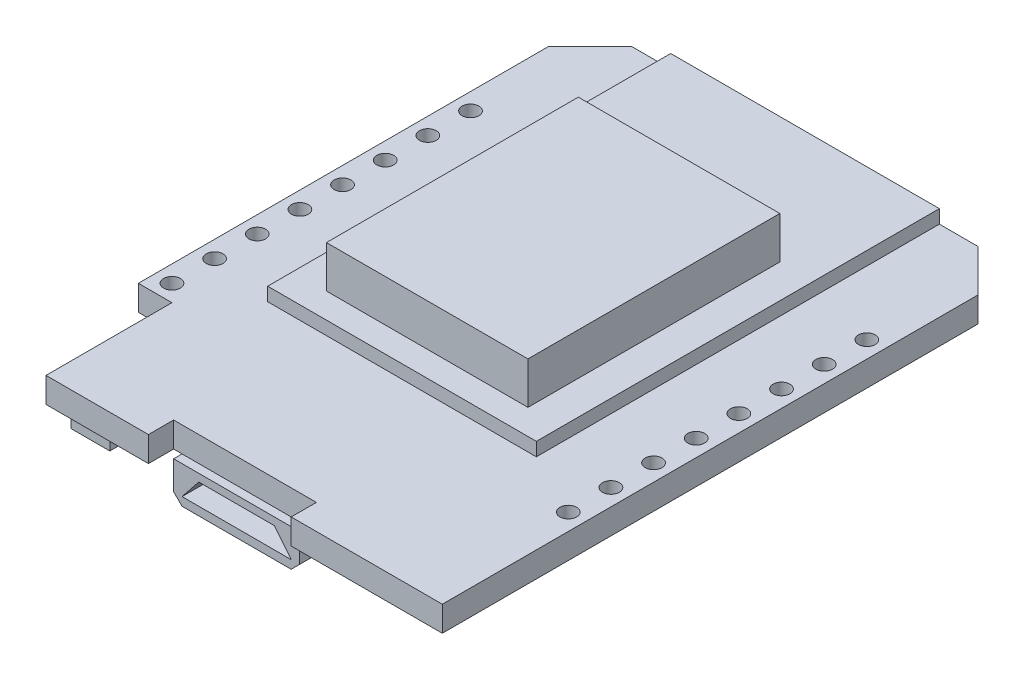
from build123d import *

# Parameters (mm, degrees)
SKETCH1_R               = 0.5
PCB_DEPTH               = 1.5
SKETCH2_W               = 16
SKETCH2_H               = 24
ESP8266_PCB_DEPTH       = 0.8
SKETCH3_W               = 12
SKETCH3_H               = 15
ESP8266_RF_SHIELD_DEPTH = 2.5
SKETCH5_W               = 7.5
SKETCH5_H               = 5.6
BOSS_EXTRUDE4_DEPTH     = 2.2
CHAMFER1_SIZE           = 0.5
CUT_EXTRUDE1_DEPTH      = 4
SKETCH5_4_W             = 2.3
SKETCH5_4_H             = 4.5
BUTTON_BODY_DEPTH       = 2
SKETCH11_W              = 2
SKETCH11_H              = 0.89493309
BUTTON_ACTUATOR_DEPTH   = 1
SKETCH5_5_W             = 1.5
SKETCH5_5_H             = 1
COMPONENTS1_DEPTH       = 1
SKETCH5_5_W_2           = 10.115707705
SKETCH5_5_H_2           = 4.574950916
COMPONENTS1_2_DEPTH     = 1
COMPONENTS1_3_DEPTH     = 1
COMPONENTS1_4_DEPTH     = 1
SKETCH5_5_W_3           = 1
SKETCH5_5_H_3           = 1.5
COMPONENTS1_5_DEPTH     = 1
SKETCH5_6_W             = 1.5
SKETCH5_6_H             = 1
COMPONENTS_2_DEPTH      = 0.5
COMPONENTS_2_2_DEPTH    = 0.5
COMPONENTS_2_3_DEPTH    = 0.5
COMPONENTS_2_4_DEPTH    = 0.5
COMPONENTS_2_5_DEPTH    = 0.5
COMPONENTS_2_6_DEPTH    = 0.5
COMPONENTS_2_7_DEPTH    = 0.5
COMPONENTS_2_8_DEPTH    = 0.5
COMPONENTS_2_9_DEPTH    = 0.5
SKETCH5_6_W_2           = 1
SKETCH5_6_H_2           = 2.730487257
COMPONENTS_2_10_DEPTH   = 0.5
COMPONENTS_2_11_DEPTH   = 0.5
SKETCH5_6_H_3           = 1.5
COMPONENTS_2_12_DEPTH   = 0.5
COMPONENTS_2_13_DEPTH   = 0.5
COMPONENTS_2_14_DEPTH   = 0.5
COMPONENTS_2_15_DEPTH   = 0.5
COMPONENTS_2_16_DEPTH   = 0.5
COMPONENTS_2_17_DEPTH   = 0.5
COMPONENTS_2_18_DEPTH   = 0.5
COMPONENTS_2_19_DEPTH   = 0.5
COMPONENTS_2_20_DEPTH   = 0.5
COMPONENTS_2_21_DEPTH   = 0.5


with BuildPart() as part:
    # Sketch1 → PCB (new body)
    with BuildSketch(Plane(origin=(0, 0, 0), x_dir=(1, 0, 0), z_dir=(0, 1, 0))):
        Polygon((0, 0), (0, 31.9), (-2.5, 34.4), (-23.1, 34.4), (-25.6, 31.9), (-25.6, 7.5), (-23.6, 7.5), (-23.6, 0), (-17.5, 0), (-17.5, 1.5), (-9, 1.5), (-9, 0), align=None)
        with Locations((-24.6, 8.5)):
            Circle(SKETCH1_R, mode=Mode.SUBTRACT)
        with Locations((-1, 8.5)):
            Circle(SKETCH1_R, mode=Mode.SUBTRACT)
        with Locations((-24.6, 11.04)):
            Circle(SKETCH1_R, mode=Mode.SUBTRACT)
        with Locations((-1, 11.04)):
            Circle(SKETCH1_R, mode=Mode.SUBTRACT)
        with Locations((-24.6, 13.58)):
            Circle(SKETCH1_R, mode=Mode.SUBTRACT)
        with Locations((-1, 13.58)):
            Circle(SKETCH1_R, mode=Mode.SUBTRACT)
        with Locations((-24.6, 16.12)):
            Circle(SKETCH1_R, mode=Mode.SUBTRACT)
        with Locations((-1, 16.12)):
            Circle(SKETCH1_R, mode=Mode.SUBTRACT)
        with Locations((-24.6, 18.66)):
            Circle(SKETCH1_R, mode=Mode.SUBTRACT)
        with Locations((-1, 18.66)):
            Circle(SKETCH1_R, mode=Mode.SUBTRACT)
        with Locations((-24.6, 21.2)):
            Circle(SKETCH1_R, mode=Mode.SUBTRACT)
        with Locations((-1, 21.2)):
            Circle(SKETCH1_R, mode=Mode.SUBTRACT)
        with Locations((-24.6, 23.74)):
            Circle(SKETCH1_R, mode=Mode.SUBTRACT)
        with Locations((-1, 23.74)):
            Circle(SKETCH1_R, mode=Mode.SUBTRACT)
        with Locations((-24.6, 26.28)):
            Circle(SKETCH1_R, mode=Mode.SUBTRACT)
        with Locations((-1, 26.28)):
            Circle(SKETCH1_R, mode=Mode.SUBTRACT)
    extrude(amount=PCB_DEPTH)


with BuildPart() as body_2:
    # Sketch2 → ESP8266 PCB (new body)
    with BuildSketch(Plane(origin=(0, 1.5, 0), x_dir=(1, 0, 0), z_dir=(0, 1, 0))):
        with Locations((-12.8, 22.4)):
            Rectangle(SKETCH2_W, SKETCH2_H)
    extrude(amount=ESP8266_PCB_DEPTH)


with BuildPart() as body_3:
    # Sketch3 → ESP8266 Rf Shield (new body)
    with BuildSketch(Plane(origin=(0, 2.3, 0), x_dir=(1, 0, 0), z_dir=(0, 1, 0))):
        with Locations((-12.8, 19.4)):
            Rectangle(SKETCH3_W, SKETCH3_H)
    extrude(amount=ESP8266_RF_SHIELD_DEPTH)


with BuildPart() as body_4:
    # Sketch5 → Boss-Extrude4 (new body)
    with BuildSketch(Plane.XZ):
        with Locations((-13.25, -3.8)):
            Rectangle(SKETCH5_W, SKETCH5_H)
    extrude(amount=BOSS_EXTRUDE4_DEPTH)

    # Chamfer1
    chamfer1_edges = [body_4.edges().sort_by_distance(p)[0] for p in [
        (-17, -2.2, -3.8),
        (-9.5, -2.2, -3.8),
    ]]
    chamfer(chamfer1_edges, length=CHAMFER1_SIZE)

    # Sketch12 → Cut-Extrude1 (cut)
    with BuildSketch(Plane.XY.offset(-1)):
        Polygon((-15.5, -0.45), (-11, -0.45), (-10, -1.7), (-16.5, -1.7), align=None)
    extrude(amount=-CUT_EXTRUDE1_DEPTH, mode=Mode.SUBTRACT)


with BuildPart() as body_5:
    # Sketch5_4 → Button Body (new body)
    with BuildSketch(Plane.XZ):
        with Locations((-22.45, -3.75)):
            Rectangle(SKETCH5_4_W, SKETCH5_4_H)
    extrude(amount=BUTTON_BODY_DEPTH)


with BuildPart() as body_6:
    # Sketch11 → Button Actuator (new body)
    with BuildSketch(Plane.ZY.offset(23.6)):
        with Locations((-3.75, -1)):
            Rectangle(SKETCH11_W, SKETCH11_H)
    extrude(amount=BUTTON_ACTUATOR_DEPTH)


with BuildPart() as body_7:
    # Sketch5_5 → Components1 (new body)
    with BuildSketch(Plane.XZ):
        with Locations((-3.164431534, -3.205591578)):
            Rectangle(SKETCH5_5_W, SKETCH5_5_H)
    extrude(amount=COMPONENTS1_DEPTH)


with BuildPart() as body_8:
    # Sketch5_5 → Components1 2 (new body)
    with BuildSketch(Plane.XZ):
        with Locations((-13.706412385, -12.112524542)):
            Rectangle(SKETCH5_5_W_2, SKETCH5_5_H_2)
    extrude(amount=COMPONENTS1_2_DEPTH)


with BuildPart() as body_9:
    # Sketch5_5 → Components1 3 (new body)
    with BuildSketch(Plane.XZ):
        with Locations((-12.85, -27.9)):
            Rectangle(SKETCH5_5_W, SKETCH5_5_H)
    extrude(amount=COMPONENTS1_3_DEPTH)


with BuildPart() as body_10:
    # Sketch5_5 → Components1 4 (new body)
    with BuildSketch(Plane.XZ):
        with Locations((-12.85, -17.9)):
            Rectangle(SKETCH5_5_W, SKETCH5_5_H)
    extrude(amount=COMPONENTS1_4_DEPTH)


with BuildPart() as body_11:
    # Sketch5_5 → Components1 5 (new body)
    with BuildSketch(Plane.XZ):
        with Locations((-7.859161772, -2.586878922)):
            Rectangle(SKETCH5_5_W_3, SKETCH5_5_H_3)
    extrude(amount=COMPONENTS1_5_DEPTH)


with BuildPart() as body_12:
    # Sketch5_6 → Components 2 (new body)
    with BuildSketch(Plane.XZ):
        with Locations((-19.35, -15.9)):
            Rectangle(SKETCH5_6_W, SKETCH5_6_H)
    extrude(amount=COMPONENTS_2_DEPTH)


with BuildPart() as body_13:
    # Sketch5_6 → Components 2 2 (new body)
    with BuildSketch(Plane.XZ):
        with Locations((-19.35, -17.9)):
            Rectangle(SKETCH5_6_W, SKETCH5_6_H)
    extrude(amount=COMPONENTS_2_2_DEPTH)


with BuildPart() as body_14:
    # Sketch5_6 → Components 2 3 (new body)
    with BuildSketch(Plane.XZ):
        with Locations((-19.35, -19.9)):
            Rectangle(SKETCH5_6_W, SKETCH5_6_H)
    extrude(amount=COMPONENTS_2_3_DEPTH)


with BuildPart() as body_15:
    # Sketch5_6 → Components 2 4 (new body)
    with BuildSketch(Plane.XZ):
        with Locations((-19.35, -21.9)):
            Rectangle(SKETCH5_6_W, SKETCH5_6_H)
    extrude(amount=COMPONENTS_2_4_DEPTH)


with BuildPart() as body_16:
    # Sketch5_6 → Components 2 5 (new body)
    with BuildSketch(Plane.XZ):
        with Locations((-19.35, -23.9)):
            Rectangle(SKETCH5_6_W, SKETCH5_6_H)
    extrude(amount=COMPONENTS_2_5_DEPTH)


with BuildPart() as body_17:
    # Sketch5_6 → Components 2 6 (new body)
    with BuildSketch(Plane.XZ):
        with Locations((-19.35, -25.9)):
            Rectangle(SKETCH5_6_W, SKETCH5_6_H)
    extrude(amount=COMPONENTS_2_6_DEPTH)


with BuildPart() as body_18:
    # Sketch5_6 → Components 2 7 (new body)
    with BuildSketch(Plane.XZ):
        with Locations((-19.35, -27.9)):
            Rectangle(SKETCH5_6_W, SKETCH5_6_H)
    extrude(amount=COMPONENTS_2_7_DEPTH)


with BuildPart() as body_19:
    # Sketch5_6 → Components 2 8 (new body)
    with BuildSketch(Plane.XZ):
        with Locations((-12.85, -23.9)):
            Rectangle(SKETCH5_6_W, SKETCH5_6_H)
    extrude(amount=COMPONENTS_2_8_DEPTH)


with BuildPart() as body_20:
    # Sketch5_6 → Components 2 9 (new body)
    with BuildSketch(Plane.XZ):
        with Locations((-12.85, -21.9)):
            Rectangle(SKETCH5_6_W, SKETCH5_6_H)
    extrude(amount=COMPONENTS_2_9_DEPTH)


with BuildPart() as body_21:
    # Sketch5_6 → Components 2 10 (new body)
    with BuildSketch(Plane.XZ):
        with Locations((-18.856957667, -6.674141125)):
            Rectangle(SKETCH5_6_W_2, SKETCH5_6_H_2)
    extrude(amount=COMPONENTS_2_10_DEPTH)


with BuildPart() as body_22:
    # Sketch5_6 → Components 2 11 (new body)
    with BuildSketch(Plane.XZ):
        with Locations((-4.664431534, -1.336878922)):
            Rectangle(SKETCH5_6_W, SKETCH5_6_H)
    extrude(amount=COMPONENTS_2_11_DEPTH)


with BuildPart() as body_23:
    # Sketch5_6 → Components 2 12 (new body)
    with BuildSketch(Plane.XZ):
        with Locations((-7.752386826, -6.644686373)):
            Rectangle(SKETCH5_6_W_2, SKETCH5_6_H_3)
    extrude(amount=COMPONENTS_2_12_DEPTH)


with BuildPart() as body_24:
    # Sketch5_6 → Components 2 13 (new body)
    with BuildSketch(Plane.XZ):
        with Locations((-3.619512743, -6.732470951)):
            Rectangle(SKETCH5_6_W, SKETCH5_6_H)
    extrude(amount=COMPONENTS_2_13_DEPTH)


with BuildPart() as body_25:
    # Sketch5_6 → Components 2 14 (new body)
    with BuildSketch(Plane.XZ):
        with Locations((-4.976980779, -10.171565746)):
            Rectangle(SKETCH5_6_W_2, SKETCH5_6_H_3)
    extrude(amount=COMPONENTS_2_14_DEPTH)


with BuildPart() as body_26:
    # Sketch5_6 → Components 2 15 (new body)
    with BuildSketch(Plane.XZ):
        with Locations((-6.576760368, -10.171565746)):
            Rectangle(SKETCH5_6_W_2, SKETCH5_6_H_3)
    extrude(amount=COMPONENTS_2_15_DEPTH)


with BuildPart() as body_27:
    # Sketch5_6 → Components 2 16 (new body)
    with BuildSketch(Plane.XZ):
        with Locations((-6.35, -13.9)):
            Rectangle(SKETCH5_6_W, SKETCH5_6_H)
    extrude(amount=COMPONENTS_2_16_DEPTH)


with BuildPart() as body_28:
    # Sketch5_6 → Components 2 17 (new body)
    with BuildSketch(Plane.XZ):
        with Locations((-6.35, -15.9)):
            Rectangle(SKETCH5_6_W, SKETCH5_6_H)
    extrude(amount=COMPONENTS_2_17_DEPTH)


with BuildPart() as body_29:
    # Sketch5_6 → Components 2 18 (new body)
    with BuildSketch(Plane.XZ):
        with Locations((-6.35, -17.9)):
            Rectangle(SKETCH5_6_W, SKETCH5_6_H)
    extrude(amount=COMPONENTS_2_18_DEPTH)


with BuildPart() as body_30:
    # Sketch5_6 → Components 2 19 (new body)
    with BuildSketch(Plane.XZ):
        with Locations((-6.35, -19.9)):
            Rectangle(SKETCH5_6_W, SKETCH5_6_H)
    extrude(amount=COMPONENTS_2_19_DEPTH)


with BuildPart() as body_31:
    # Sketch5_6 → Components 2 20 (new body)
    with BuildSketch(Plane.XZ):
        with Locations((-6.35, -25.9)):
            Rectangle(SKETCH5_6_W, SKETCH5_6_H)
    extrude(amount=COMPONENTS_2_20_DEPTH)


with BuildPart() as body_32:
    # Sketch5_6 → Components 2 21 (new body)
    with BuildSketch(Plane.XZ):
        with Locations((-6.35, -27.9)):
            Rectangle(SKETCH5_6_W, SKETCH5_6_H)
    extrude(amount=COMPONENTS_2_21_DEPTH)


solid = Compound([part.part, body_2.part, body_3.part, body_4.part, body_5.part, body_6.part, body_7.part, body_8.part, body_9.part, body_10.part, body_11.part, body_12.part, body_13.part, body_14.part, body_15.part, body_16.part, body_17.part, body_18.part, body_19.part, body_20.part, body_21.part, body_22.part, body_23.part, body_24.part, body_25.part, body_26.part, body_27.part, body_28.part, body_29.part, body_30.part, body_31.part, body_32.part])
